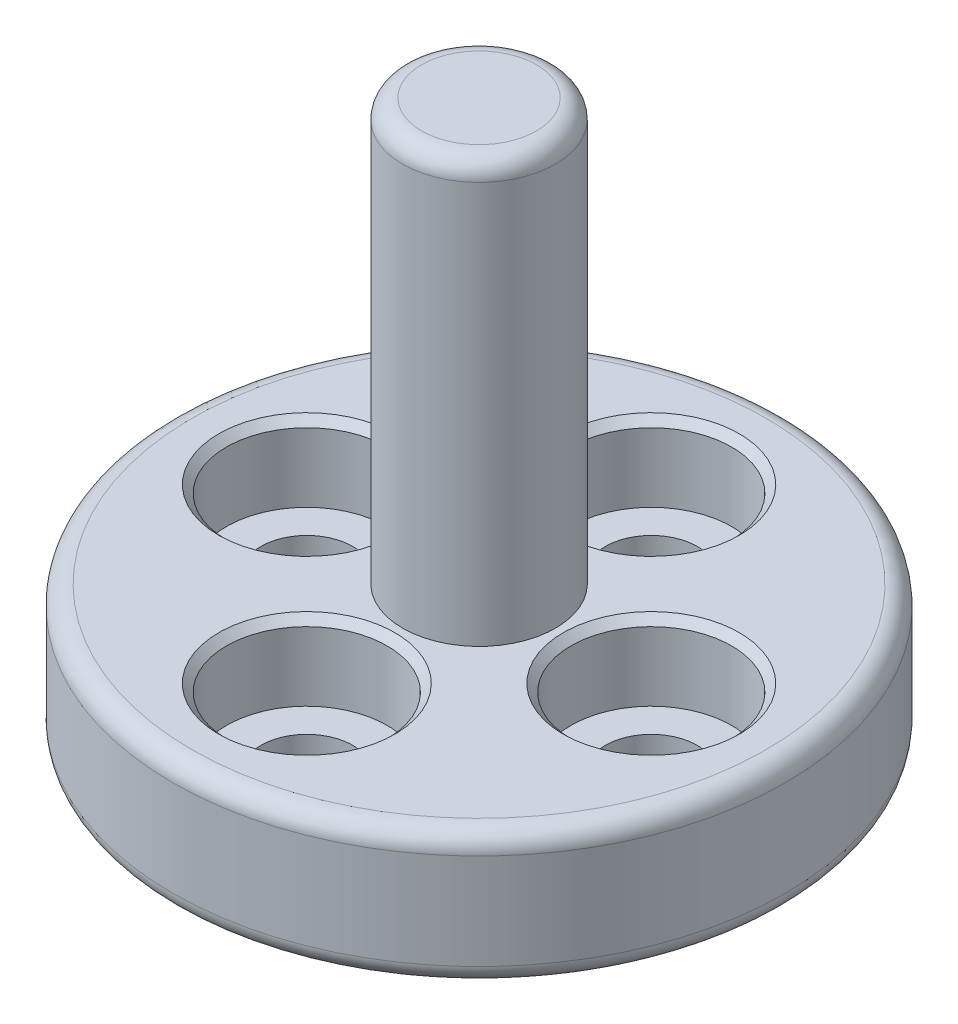
from build123d import *

# Parameters (mm, degrees)
SKETCH1_R           = 8
BOSS_EXTRUDE1_DEPTH = 3.5
SKETCH2_R           = 2
BOSS_EXTRUDE2_DEPTH = 11
SKETCH4_R           = 1.2
CUT_EXTRUDE1_DEPTH  = 4.5
SKETCH5_R           = 2.1
CUT_EXTRUDE2_DEPTH  = 2
CHAMFER2_SIZE       = 0.2
FILLET3_R           = 0.5
FILLET4_R           = 0.5


with BuildPart() as part:
    # Sketch1 → Boss-Extrude1 (new body)
    with BuildSketch(Plane(origin=(0, 0, 0), x_dir=(1, 0, 0), z_dir=(0, 1, 0))):
        Circle(SKETCH1_R)
    extrude(amount=BOSS_EXTRUDE1_DEPTH)

    # Sketch2 → Boss-Extrude2 (add)
    with BuildSketch(Plane(origin=(0, 3.5, 0), x_dir=(1, 0, 0), z_dir=(0, 1, 0))):
        Circle(SKETCH2_R)
    extrude(amount=BOSS_EXTRUDE2_DEPTH)

    # Sketch4 → Cut-Extrude1 (cut, through all)
    with BuildSketch(Plane(origin=(0, 3.5, 0), x_dir=(1, 0, 0), z_dir=(0, 1, 0))):
        with Locations((0, 4.5)):
            Circle(SKETCH4_R)
        with Locations((4.5, 0)):
            Circle(SKETCH4_R)
        with Locations((0, -4.5)):
            Circle(SKETCH4_R)
        with Locations((-4.5, 0)):
            Circle(SKETCH4_R)
    extrude(amount=-CUT_EXTRUDE1_DEPTH, mode=Mode.SUBTRACT)

    # Sketch5 → Cut-Extrude2 (cut)
    with BuildSketch(Plane(origin=(0, 3.5, 0), x_dir=(1, 0, 0), z_dir=(0, 1, 0))):
        with Locations((0, 4.5)):
            Circle(SKETCH5_R)
        with Locations((4.5, 0)):
            Circle(SKETCH5_R)
        with Locations((0, -4.5)):
            Circle(SKETCH5_R)
        with Locations((-4.5, 0)):
            Circle(SKETCH5_R)
    extrude(amount=-CUT_EXTRUDE2_DEPTH, mode=Mode.SUBTRACT)

    # Chamfer2
    chamfer2_edges = [part.edges().sort_by_distance(p)[0] for p in [
        (-2.1, 3.5, -4.5),
        (2.4, 3.5, 0),
        (-2.1, 3.5, 4.5),
        (-6.6, 3.5, 0),
    ]]
    chamfer(chamfer2_edges, length=CHAMFER2_SIZE)

    # Fillet3
    fillet3_edges = [part.edges().sort_by_distance(p)[0] for p in [
        (-2, 14.5, 0),
    ]]
    fillet(fillet3_edges, radius=FILLET3_R)

    # Fillet4
    fillet4_edges = [part.edges().sort_by_distance(p)[0] for p in [
        (-8, 0, 0),
        (-8, 3.5, 0),
    ]]
    fillet(fillet4_edges, radius=FILLET4_R)


solid = part.part
